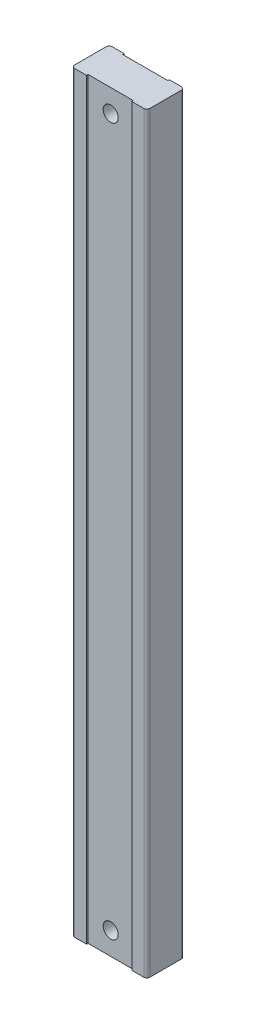
from build123d import *

# Parameters (mm, degrees)
BOSS_EXTRUDE1_DEPTH              = 500
SKETCH3_W                        = 30
SKETCH3_H                        = 1
CUT_EXTRUDE1_DEPTH               = 500
M10X1_0_TAPPED_HOLE1_D           = 9
M10X1_0_TAPPED_HOLE1_DEPTH       = 51.26
M10X1_0_TAPPED_HOLE1_CBORE_D     = 10
M10X1_0_TAPPED_HOLE1_CBORE_DEPTH = 45.4
M10X1_0_TAPPED_HOLE1_TIP         = 2.703872786


with BuildPart() as part:
    # Sketch1 → Boss-Extrude1 (new body)
    with BuildSketch(Plane(origin=(0, 0, 0), x_dir=(1, 0, 0), z_dir=(0, 1, 0))):
        with BuildLine():
            Line((-73.903884132, 1.690933219), (-27.903884132, 1.690933219))
            ThreePointArc((-27.903884132, 1.690933219), (-26.48967057, 1.105146782), (-25.903884132, -0.309066781))
            Line((-25.903884132, -0.309066781), (-25.903884132, -21.309066781))
            ThreePointArc((-25.903884132, -21.309066781), (-26.48967057, -22.723280343), (-27.903884132, -23.309066781))
            Line((-27.903884132, -23.309066781), (-73.903884132, -23.309066781))
            ThreePointArc((-73.903884132, -23.309066781), (-75.318097695, -22.723280343), (-75.903884132, -21.309066781))
            Line((-75.903884132, -21.309066781), (-75.903884132, -0.309066781))
            ThreePointArc((-75.903884132, -0.309066781), (-75.318097695, 1.105146782), (-73.903884132, 1.690933219))
        make_face()
    extrude(amount=BOSS_EXTRUDE1_DEPTH)

    # Sketch3 → Cut-Extrude1 (cut)
    with BuildSketch(Plane(origin=(0, 500, 0), x_dir=(1, 0, 0), z_dir=(0, 1, 0))):
        with Locations((-50.903884132, 1.190933219)):
            Rectangle(SKETCH3_W, SKETCH3_H)
        with Locations((-50.903884132, -22.809066781)):
            Rectangle(SKETCH3_W, SKETCH3_H)
    extrude(amount=-CUT_EXTRUDE1_DEPTH, mode=Mode.SUBTRACT)

    # M10x1.0 Tapped Hole1
    with Locations(Plane(origin=(-50.903884132, 485, 22.309066781), x_dir=(1, 0, 0), z_dir=(0, 0, 1))):
        with Locations((0, 0), (0, -470)):
            CounterBoreHole(M10X1_0_TAPPED_HOLE1_D / 2, M10X1_0_TAPPED_HOLE1_CBORE_D / 2, M10X1_0_TAPPED_HOLE1_CBORE_DEPTH, depth=M10X1_0_TAPPED_HOLE1_DEPTH)
            with Locations((0, 0, -(M10X1_0_TAPPED_HOLE1_DEPTH + M10X1_0_TAPPED_HOLE1_TIP / 2))):  # 118° drill point
                Cone(0, M10X1_0_TAPPED_HOLE1_D / 2, M10X1_0_TAPPED_HOLE1_TIP, mode=Mode.SUBTRACT)


solid = part.part
